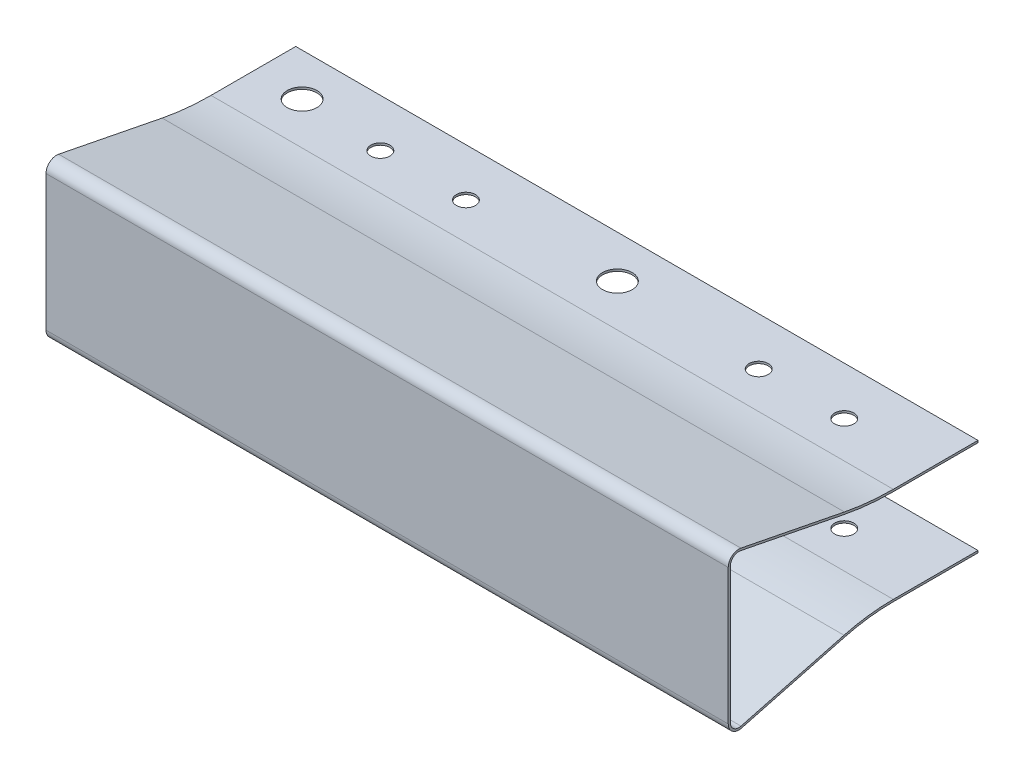
from build123d import *

# Parameters (mm, degrees)
EXTRUDE1_DEPTH          = 40.25
SKETCH2_R               = 1.75
SKETCH2_R_2             = 1.125
CUT_EXTRUDE1_DEPTH      = 10.25
CUT_EXTRUDE1_DEPTH_BACK = 10.25


with BuildPart() as part:
    # Sketch1 → Extrude1 (new body, symmetric)
    with BuildSketch(Plane(origin=(0, 0, 0), x_dir=(0, 0, -1), z_dir=(1, 0, 0))):
        with BuildLine():
            Line((-24.22, 8), (-24.22, -8))
            ThreePointArc((-24.22, -8), (-23.830111825, -8.792315317), (-22.964472878, -8.966801888))
            Line((-22.964472878, -8.966801888), (-10.813561051, -5.755298505))
            ThreePointArc((-10.813561051, -5.755298505), (-7.931209986, -5.189614776), (-5, -5))
            Line((-5, -5), (5, -5))
            Line((5, -5), (5, -5.25))
            Line((5, -5.25), (-5, -5.25))
            ThreePointArc((-5, -5.25), (-7.899000655, -5.437531211), (-10.749679271, -5.996998977))
            Line((-10.749679271, -5.996998977), (-22.900591097, -9.208502359))
            ThreePointArc((-22.900591097, -9.208502359), (-23.982639781, -8.990394146), (-24.47, -8))
            Line((-24.47, -8), (-24.47, 8))
            ThreePointArc((-24.47, 8), (-24.013634161, 8.965735377), (-22.97776829, 9.226304937))
            Line((-22.97776829, 9.226304937), (-10.765114709, 6.8139425))
            ThreePointArc((-10.765114709, 6.8139425), (-7.896315709, 6.391321284), (-5, 6.25))
            Line((-5, 6.25), (5, 6.25))
            Line((5, 6.25), (5, 6))
            Line((5, 6), (-5, 6))
            ThreePointArc((-5, 6), (-7.920654497, 6.142508858), (-10.813561051, 6.568681513))
            Line((-10.813561051, 6.568681513), (-23.026214632, 8.98104395))
            ThreePointArc((-23.026214632, 8.98104395), (-23.854907329, 8.772588302), (-24.22, 8))
        make_face()
    extrude(amount=EXTRUDE1_DEPTH, both=True)

    # Sketch2 → Cut-Extrude1 (cut, two sides)
    with BuildSketch(Plane(origin=(0, 0, 0), x_dir=(1, 0, 0), z_dir=(0, 1, 0))) as cut_extrude1_sk:
        with Locations(Location((-34.5, 0, 0), (0, 0, 270))):  # turned: the seam where the file's is
            Circle(SKETCH2_R)
        with Locations(Location((-24.62, -0.65, 0), (0, 0, 270))):  # turned: the seam where the file's is
            Circle(SKETCH2_R_2)
        with Locations(Location((-14.52, -0.65, 0), (0, 0, 270))):  # turned: the seam where the file's is
            Circle(SKETCH2_R_2)
        with Locations(Location((2.7, 0, 0), (0, 0, 270))):  # turned: the seam where the file's is
            Circle(SKETCH2_R)
        with Locations(Location((20.02, -0.65, 0), (0, 0, 270))):  # turned: the seam where the file's is
            Circle(SKETCH2_R_2)
        with Locations(Location((30.12, -0.65, 0), (0, 0, 270))):  # turned: the seam where the file's is
            Circle(SKETCH2_R_2)
    extrude(amount=CUT_EXTRUDE1_DEPTH, mode=Mode.SUBTRACT)
    extrude(cut_extrude1_sk.sketch, amount=-CUT_EXTRUDE1_DEPTH_BACK, mode=Mode.SUBTRACT)


solid = part.part
